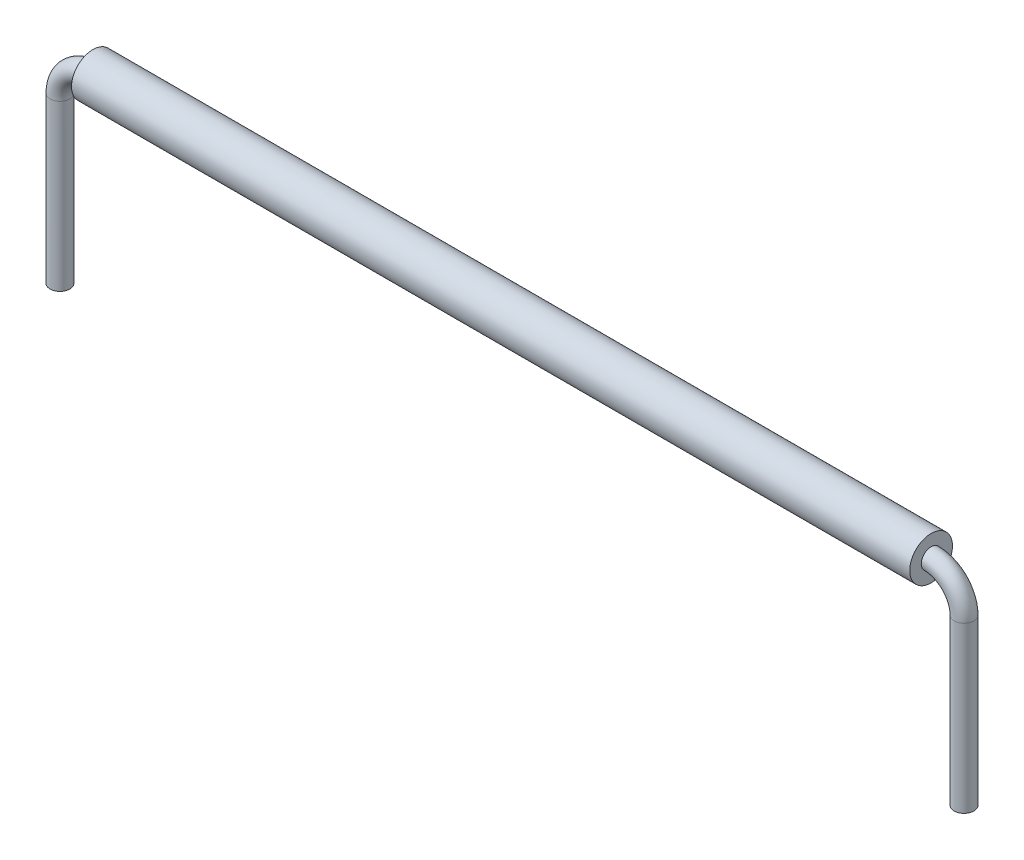
from build123d import *

# Parameters (mm, degrees)
SKETCH2_R                = 0.3
SKETCH3_R                = 0.65
SKETCH3_R_2              = 0.3
BOSS_EXTRUDE1_DEPTH      = 12.7275
BOSS_EXTRUDE1_DEPTH_BACK = 12.7275


with BuildPart() as part:
    # Sweep1: sweep along a path in Sketch1
    with BuildLine(Plane.XY) as sweep1_path:
        Line((-13.7275, -6), (-13.7275, -1))
        ThreePointArc((-13.7275, -1), (-13.434606781, -0.292893219), (-12.7275, 0))
        Line((-12.7275, 0), (12.7275, 0))
        ThreePointArc((12.7275, 0), (13.434606781, -0.292893219), (13.7275, -1))
        Line((13.7275, -1), (13.7275, -6))
    # Sketch2 → Sweep1 (sweep)
    with BuildSketch(Plane(origin=(0, 0, 0), x_dir=(0, 0, -1), z_dir=(1, 0, 0))):
        Circle(SKETCH2_R)
    sweep(path=sweep1_path.line)


with BuildPart() as body_2:
    # Sketch3 → Boss-Extrude1 (new body, two sides)
    with BuildSketch(Plane(origin=(0, 0, 0), x_dir=(0, 0, -1), z_dir=(1, 0, 0))) as boss_extrude1_sk:
        Circle(SKETCH3_R)
        Circle(SKETCH3_R_2, mode=Mode.SUBTRACT)
    extrude(amount=BOSS_EXTRUDE1_DEPTH)
    extrude(boss_extrude1_sk.sketch, amount=-BOSS_EXTRUDE1_DEPTH_BACK)


solid = Compound([part.part, body_2.part])
